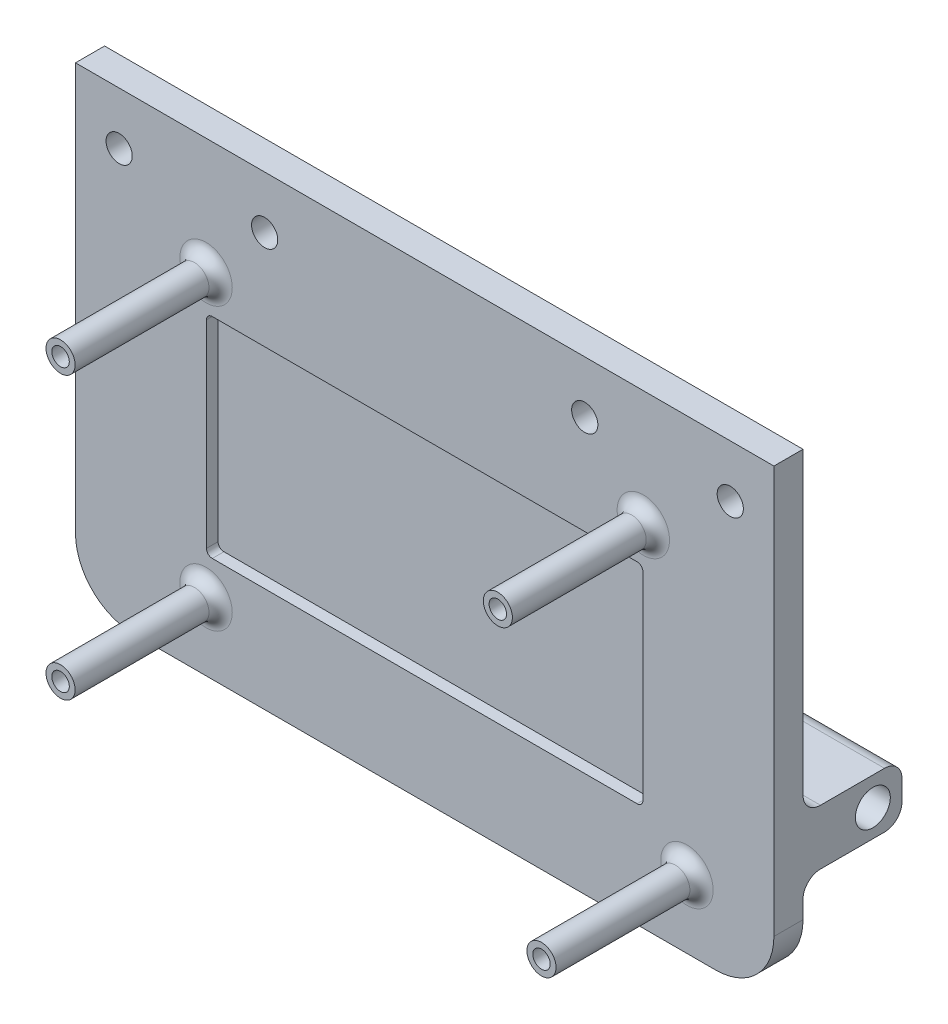
from build123d import *

# Parameters (mm, degrees)
SKETCH1_W            = 120
SKETCH1_H            = 80
BOSS_EXTRUDE1_DEPTH  = 2.5
FILLET1_R            = 10
SKETCH2_R            = 2.25
CUT_EXTRUDE1_DEPTH   = 6
SKETCH3_R            = 2.5
SKETCH3_R_2          = 1.5
BOSS_EXTRUDE2_DEPTH  = 25
FILLET2_R            = 2
CUT_EXTRUDE2_DEPTH   = 2
SKETCH6_W            = 17
SKETCH6_H            = 9.5
SKETCH6_R            = 3
BOSS_EXTRUDE3_DEPTH  = 30
FILLET3_R            = 3
FILLET3_OF_MIRROR1_R = 3


with BuildPart() as part:
    # Sketch1 → Boss-Extrude1 (new body, symmetric)
    with BuildSketch(Plane.XY):
        with Locations((0, -40)):
            Rectangle(SKETCH1_W, SKETCH1_H)
    extrude(amount=BOSS_EXTRUDE1_DEPTH, both=True)

    # Fillet1
    fillet1_edges = [part.edges().sort_by_distance(p)[0] for p in [
        (60, -80, 0),
        (-60, -80, 0),
    ]]
    fillet(fillet1_edges, radius=FILLET1_R)

    # Sketch2 → Cut-Extrude1 (cut, through all)
    with BuildSketch(Plane.XY.offset(2.5)):
        with Locations((-52.5, -9)):
            Circle(SKETCH2_R)
        with Locations((-27.5, -9)):
            Circle(SKETCH2_R)
        with Locations((27.5, -9)):
            Circle(SKETCH2_R)
        with Locations((52.5, -9)):
            Circle(SKETCH2_R)
    extrude(amount=-CUT_EXTRUDE1_DEPTH, mode=Mode.SUBTRACT)

    # Sketch3 → Boss-Extrude2 (add)
    with BuildSketch(Plane.XY.offset(2.5)):
        with Locations((-37.565, -20)):
            Circle(SKETCH3_R)
        with Locations((-37.565, -20)):
            Circle(SKETCH3_R_2, mode=Mode.SUBTRACT)
        with Locations((37.565, -20)):
            Circle(SKETCH3_R)
        with Locations((37.565, -20)):
            Circle(SKETCH3_R_2, mode=Mode.SUBTRACT)
        with Locations((-37.565, -68.34)):
            Circle(SKETCH3_R)
        with Locations((-37.565, -68.34)):
            Circle(SKETCH3_R_2, mode=Mode.SUBTRACT)
        with Locations((45.065, -68.34)):
            Circle(SKETCH3_R)
        with Locations((45.065, -68.34)):
            Circle(SKETCH3_R_2, mode=Mode.SUBTRACT)
    extrude(amount=BOSS_EXTRUDE2_DEPTH)

    # Fillet2
    fillet2_edges = [part.edges().sort_by_distance(p)[0] for p in [
        (-40.065, -20, 2.5),
        (35.065, -20, 2.5),
        (-40.065, -68.34, 2.5),
        (42.565, -68.34, 2.5),
    ]]
    fillet(fillet2_edges, radius=FILLET2_R)

    # Sketch4 → Cut-Extrude2 (cut)
    with BuildSketch(Plane.XY.offset(2.5)):
        with BuildLine():
            Line((-36.5, -62), (36.5, -62))
            ThreePointArc((36.5, -62), (37.207106781, -61.707106781), (37.5, -61))
            Line((37.5, -61), (37.5, -27))
            ThreePointArc((37.5, -27), (37.207106781, -26.292893219), (36.5, -26))
            Line((36.5, -26), (-36.5, -26))
            ThreePointArc((-36.5, -26), (-37.207106781, -26.292893219), (-37.5, -27))
            Line((-37.5, -27), (-37.5, -61))
            ThreePointArc((-37.5, -61), (-37.207106781, -61.707106781), (-36.5, -62))
        make_face()
    extrude(amount=-CUT_EXTRUDE2_DEPTH, mode=Mode.SUBTRACT)

    # Sketch6 → Boss-Extrude3 (add)
    with BuildSketch(Plane(origin=(60, 0, 0), x_dir=(0, 0, -1), z_dir=(1, 0, 0))):
        with Locations((11, -59.221502787)):
            Rectangle(SKETCH6_W, SKETCH6_H)
        with Locations((14.5, -59.320826281)):
            Circle(SKETCH6_R, mode=Mode.SUBTRACT)
    boss_extrude3 = extrude(amount=-BOSS_EXTRUDE3_DEPTH)

    # Fillet3
    fillet3_edges = [part.edges().sort_by_distance(p)[0] for p in [
        (45, -54.471502787, -2.5),
        (45, -54.471502787, -19.5),
        (45, -63.971502787, -19.5),
        (45, -63.971502787, -2.5),
    ]]
    fillet(fillet3_edges, radius=FILLET3_R)

    # Mirror1: Boss-Extrude3 across plane
    add(boss_extrude3.mirror(Plane(origin=(0, 0, 0), x_dir=(0, 0, 1), z_dir=(1, 0, 0))))

    # Fillet3 of Mirror1
    fillet3_of_mirror1_edges = [part.edges().sort_by_distance(p)[0] for p in [
        (-45, -54.471502787, -2.5),
        (-45, -54.471502787, -19.5),
        (-45, -63.971502787, -19.5),
        (-45, -63.971502787, -2.5),
    ]]
    fillet(fillet3_of_mirror1_edges, radius=FILLET3_OF_MIRROR1_R)


solid = part.part
